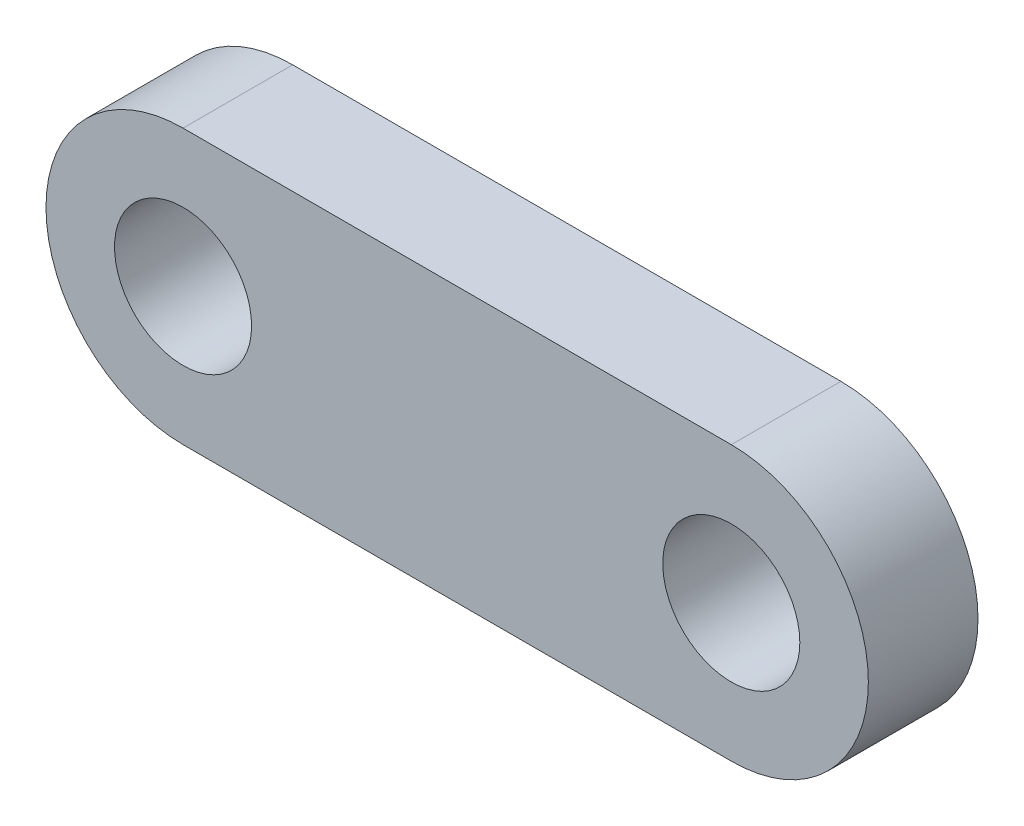
from build123d import *

# Parameters (mm, degrees)
SKETCH1_R           = 3.175
BOSS_EXTRUDE1_DEPTH = 5.08


with BuildPart() as part:
    # Sketch1 → Boss-Extrude1 (new body)
    with BuildSketch(Plane.XY):
        with BuildLine():
            Line((-12.7, 6.35), (12.7, 6.35))
            ThreePointArc((12.7, 6.35), (19.05, 0), (12.7, -6.35))
            Line((12.7, -6.35), (-12.7, -6.35))
            ThreePointArc((-12.7, -6.35), (-19.05, 0), (-12.7, 6.35))
        make_face()
        with Locations((-12.7, 0)):
            Circle(SKETCH1_R, mode=Mode.SUBTRACT)
        with Locations((12.7, 0)):
            Circle(SKETCH1_R, mode=Mode.SUBTRACT)
    extrude(amount=BOSS_EXTRUDE1_DEPTH)


solid = part.part
